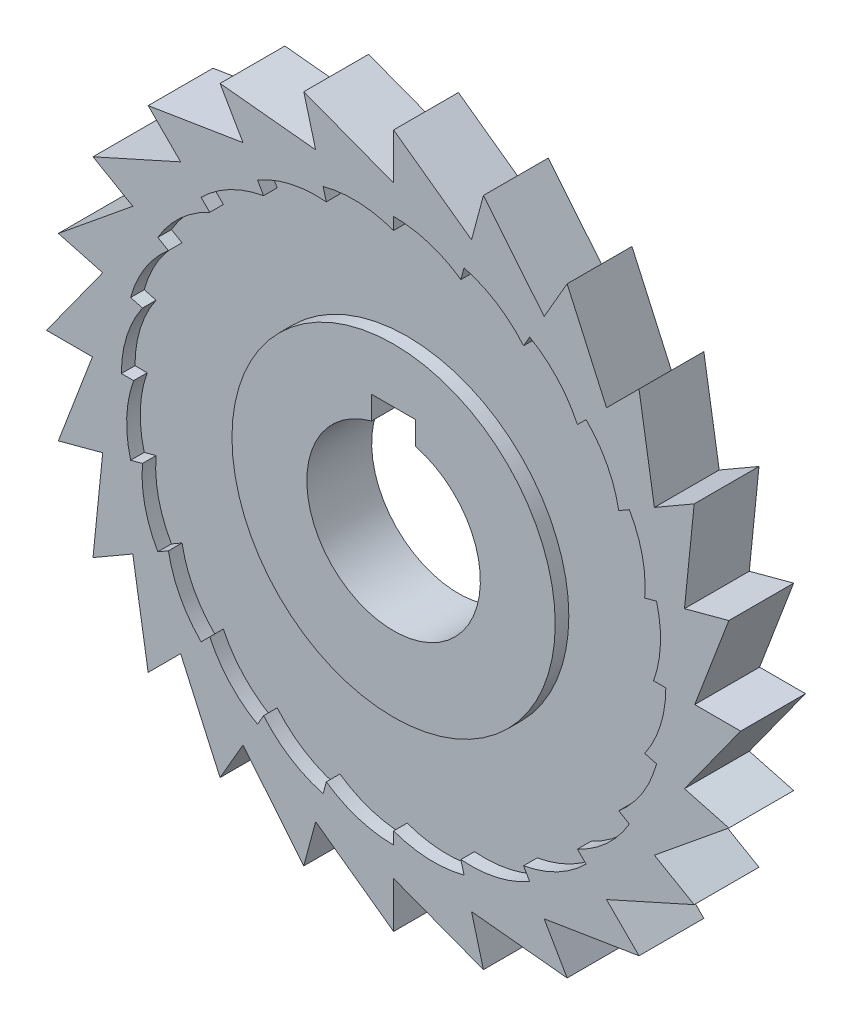
from build123d import *

# Parameters (mm, degrees)
CROQUIS1_R                   = 23.75
CROQUIS1_R_2                 = 40
SALIENTE_EXTRUIR1_DEPTH      = 5.525
CROQUIS3_R                   = 23.75
SALIENTE_EXTRUIR3_DEPTH      = 4.7625
SALIENTE_EXTRUIR3_DEPTH_BACK = 4.7625
SALIENTE_EXTRUIR9_DEPTH      = 4.7625
SALIENTE_EXTRUIR9_DEPTH_BACK = 4.7625


with BuildPart() as part:
    # Croquis1 → Saliente-Extruir1 (new body)
    with BuildSketch(Plane.XY):
        Circle(CROQUIS1_R)
        with BuildLine():
            ThreePointArc((-3.25, 12.328828006), (0, -12.75), (3.25, 12.328828006))
            Line((3.25, 12.328828006), (3.25, 15.75))
            Line((3.25, 15.75), (-3.25, 15.75))
            Line((-3.25, 15.75), (-3.25, 12.328828006))
        make_face(mode=Mode.SUBTRACT)
        Circle(CROQUIS1_R_2)
        Circle(CROQUIS1_R, mode=Mode.SUBTRACT)
    extrude(amount=SALIENTE_EXTRUIR1_DEPTH)

    # Croquis3 → Saliente-Extruir3 (add, two sides)
    with BuildSketch(Plane.XY.offset(2.7625)) as saliente_extruir3_sk:
        Circle(CROQUIS3_R)
        with BuildLine():
            Line((-3.25, 15.75), (-3.25, 12.328828006))
            ThreePointArc((-3.25, 12.328828006), (0, -12.75), (3.25, 12.328828006))
            Line((3.25, 12.328828006), (3.25, 15.75))
            Line((3.25, 15.75), (-3.25, 15.75))
        make_face(mode=Mode.SUBTRACT)
    extrude(amount=SALIENTE_EXTRUIR3_DEPTH)
    extrude(saliente_extruir3_sk.sketch, amount=-SALIENTE_EXTRUIR3_DEPTH_BACK)

    # Croquis5 → Saliente-Extruir9 (add, two sides)
    with BuildSketch(Plane.XY.offset(2.7625)) as saliente_extruir9_sk:
        Polygon((11.452742746, -42.742217813), (25.5, -44.167295593), (22.125, -38.321624117), (36.062445841, -36.062445841), (31.289475068, -31.289475068), (44.167295593, -25.5), (38.321624117, -22.125), (49.262217141, -13.1997713), (42.742217813, -11.452742746), (51, 0), (44.25, 0), (49.262217141, 13.1997713), (42.742217813, 11.452742746), (44.167295593, 25.5), (38.321624117, 22.125), (36.062445841, 36.062445841), (31.289475068, 31.289475068), (25.5, 44.167295593), (22.125, 38.321624117), (13.1997713, 49.262217141), (11.452742746, 42.742217813), (0, 51), (0, 44.25), (-13.1997713, 49.262217141), (-11.452742746, 42.742217813), (-25.5, 44.167295593), (-22.125, 38.321624117), (-36.062445841, 36.062445841), (-31.289475068, 31.289475068), (-44.167295593, 25.5), (-38.321624117, 22.125), (-49.262217141, 13.1997713), (-42.742217813, 11.452742746), (-51, 0), (-44.25, 0), (-49.262217141, -13.1997713), (-42.742217813, -11.452742746), (-44.167295593, -25.5), (-38.321624117, -22.125), (-36.062445841, -36.062445841), (-31.289475068, -31.289475068), (-25.5, -44.167295593), (-22.125, -38.321624117), (-13.1997713, -49.262217141), (-11.452742746, -42.742217813), (0, -51), (0, -44.25), (13.1997713, -49.262217141), align=None)
        with BuildLine():
            Line((0, 38.2), (0, 40))
            ThreePointArc((0, 40), (5.180991094, 39.20639841), (9.886887523, 36.898366564))
            Line((9.886887523, 36.898366564), (10.352761804, 38.637033052))
            ThreePointArc((10.352761804, 38.637033052), (15.151815702, 36.529533612), (19.1, 33.082170425))
            Line((19.1, 33.082170425), (20, 34.641016151))
            ThreePointArc((20, 34.641016151), (24.090069109, 31.363241467), (27.011479041, 27.011479041))
            Line((27.011479041, 27.011479041), (28.284271247, 28.284271247))
            ThreePointArc((28.284271247, 28.284271247), (31.386624117, 24.059596246), (33.082170425, 19.1))
            Line((33.082170425, 19.1), (34.641016151, 20))
            ThreePointArc((34.641016151, 20), (36.544232561, 15.116329301), (36.898366564, 9.886887523))
            Line((36.898366564, 9.886887523), (38.637033052, 10.352761804))
            ThreePointArc((38.637033052, 10.352761804), (39.211411947, 5.142909495), (38.2, 0))
            Line((38.2, 0), (40, 0))
            ThreePointArc((40, 0), (39.20639841, -5.180991094), (36.898366564, -9.886887523))
            Line((36.898366564, -9.886887523), (38.637033052, -10.352761804))
            ThreePointArc((38.637033052, -10.352761804), (36.529533612, -15.151815702), (33.082170425, -19.1))
            Line((33.082170425, -19.1), (34.641016151, -20))
            ThreePointArc((34.641016151, -20), (31.363241467, -24.090069109), (27.011479041, -27.011479041))
            Line((27.011479041, -27.011479041), (28.284271247, -28.284271247))
            ThreePointArc((28.284271247, -28.284271247), (24.059596246, -31.386624117), (19.1, -33.082170425))
            Line((19.1, -33.082170425), (20, -34.641016151))
            ThreePointArc((20, -34.641016151), (15.116329301, -36.544232561), (9.886887523, -36.898366564))
            Line((9.886887523, -36.898366564), (10.352761804, -38.637033052))
            ThreePointArc((10.352761804, -38.637033052), (5.142909495, -39.211411947), (0, -38.2))
            Line((0, -38.2), (0, -40))
            ThreePointArc((0, -40), (-5.180991094, -39.20639841), (-9.886887523, -36.898366564))
            Line((-9.886887523, -36.898366564), (-10.352761804, -38.637033052))
            ThreePointArc((-10.352761804, -38.637033052), (-15.151815702, -36.529533612), (-19.1, -33.082170425))
            Line((-19.1, -33.082170425), (-20, -34.641016151))
            ThreePointArc((-20, -34.641016151), (-24.090069109, -31.363241467), (-27.011479041, -27.011479041))
            Line((-27.011479041, -27.011479041), (-28.284271247, -28.284271247))
            ThreePointArc((-28.284271247, -28.284271247), (-31.386624117, -24.059596246), (-33.082170425, -19.1))
            Line((-33.082170425, -19.1), (-34.641016151, -20))
            ThreePointArc((-34.641016151, -20), (-36.544232561, -15.116329301), (-36.898366564, -9.886887523))
            Line((-36.898366564, -9.886887523), (-38.637033052, -10.352761804))
            ThreePointArc((-38.637033052, -10.352761804), (-39.211411947, -5.142909495), (-38.2, 0))
            Line((-38.2, 0), (-40, 0))
            ThreePointArc((-40, 0), (-39.20639841, 5.180991094), (-36.898366564, 9.886887523))
            Line((-36.898366564, 9.886887523), (-38.637033052, 10.352761804))
            ThreePointArc((-38.637033052, 10.352761804), (-36.529533612, 15.151815702), (-33.082170425, 19.1))
            Line((-33.082170425, 19.1), (-34.641016151, 20))
            ThreePointArc((-34.641016151, 20), (-31.363241467, 24.090069109), (-27.011479041, 27.011479041))
            Line((-27.011479041, 27.011479041), (-28.284271247, 28.284271247))
            ThreePointArc((-28.284271247, 28.284271247), (-24.059596246, 31.386624117), (-19.1, 33.082170425))
            Line((-19.1, 33.082170425), (-20, 34.641016151))
            ThreePointArc((-20, 34.641016151), (-15.116329301, 36.544232561), (-9.886887523, 36.898366564))
            Line((-9.886887523, 36.898366564), (-10.352761804, 38.637033052))
            ThreePointArc((-10.352761804, 38.637033052), (-5.142909495, 39.211411947), (0, 38.2))
        make_face(mode=Mode.SUBTRACT)
    extrude(amount=SALIENTE_EXTRUIR9_DEPTH)
    extrude(saliente_extruir9_sk.sketch, amount=-SALIENTE_EXTRUIR9_DEPTH_BACK)


solid = part.part
